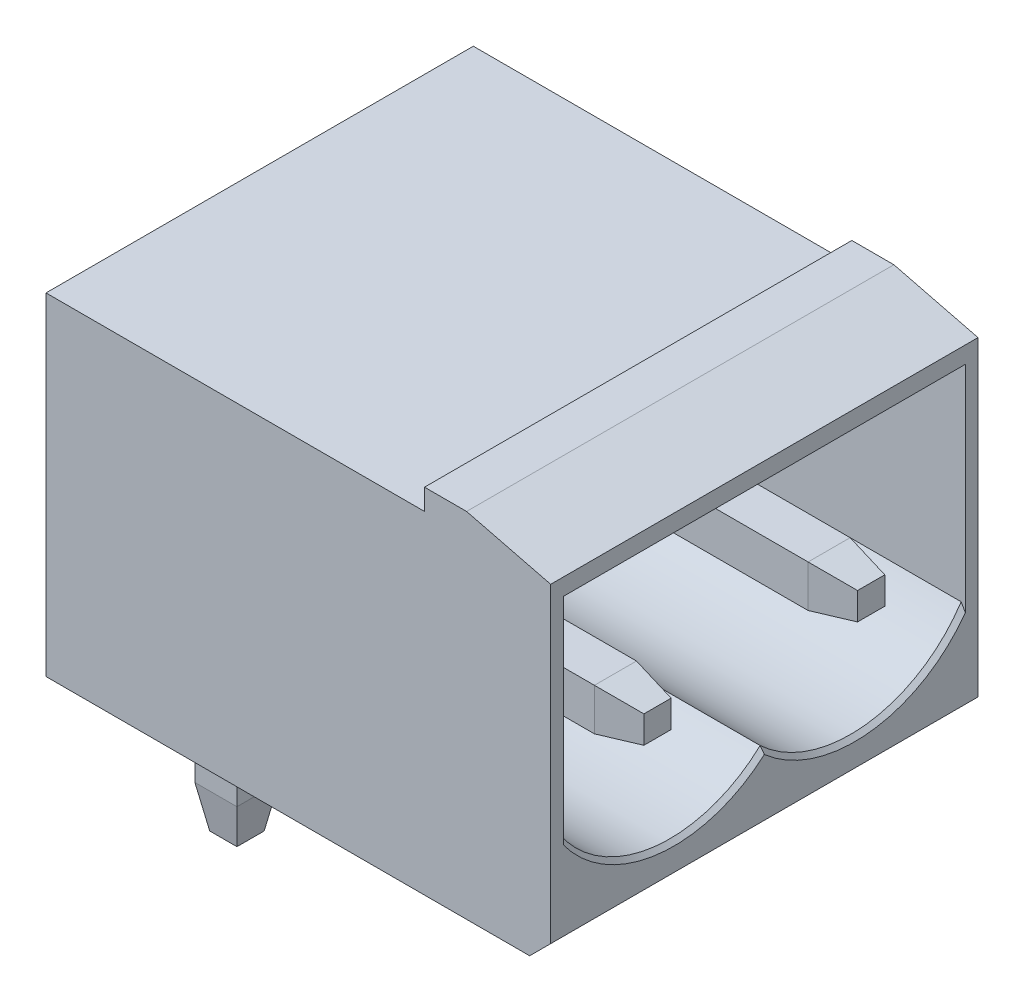
from build123d import *

# Parameters (mm, degrees)
SKIZZE3_W                       = 12
SKIZZE3_H                       = 7.9
AUFSATZ_LINEAR_AUSTRAGEN2_DEPTH = 10.16
AUFSATZ_LINEAR_AUSTRAGEN3_DEPTH = 10.16
SCHNITT_LINEAR_AUSTRAGEN1_DEPTH = 9
SKIZZE6_W                       = 1
SKIZZE6_H                       = 1
AUFSATZ_LINEAR_AUSTRAGEN4_DEPTH = 3.45
SKIZZE7_W                       = 1
SKIZZE7_H                       = 1
AUFSATZ_LINEAR_AUSTRAGEN5_DEPTH = 9
FASE1_SIZE                      = 1
FASE1_SIZE2                     = 0.176326981
FASE1_PART_2_SIZE               = 1
FASE1_PART_2_SIZE2              = 0.176326981
FASE1_PART_3_SIZE               = 1
FASE1_PART_3_SIZE2              = 0.176326981
FASE1_PART_4_SIZE               = 1
FASE1_PART_4_SIZE2              = 0.176326981
FASE1_PART_5_SIZE               = 1
FASE1_PART_5_SIZE2              = 0.176326981
FASE1_PART_6_SIZE               = 1
FASE1_PART_6_SIZE2              = 0.176326981
FASE1_PART_7_SIZE               = 1
FASE1_PART_7_SIZE2              = 0.176326981
FASE1_PART_8_SIZE               = 1
FASE1_PART_8_SIZE2              = 0.176326981
FASE14_SIZE                     = 1
FASE14_SIZE2                    = 0.176326981
FASE14_PART_2_SIZE              = 1
FASE14_PART_2_SIZE2             = 0.176326981
FASE14_PART_3_SIZE              = 1
FASE14_PART_3_SIZE2             = 0.176326981
FASE14_PART_4_SIZE              = 1
FASE14_PART_4_SIZE2             = 0.176326981
FASE14_PART_5_SIZE              = 1
FASE14_PART_5_SIZE2             = 0.176326981
FASE14_PART_6_SIZE              = 1
FASE14_PART_6_SIZE2             = 0.176326981
FASE14_PART_7_SIZE              = 1
FASE14_PART_7_SIZE2             = 0.176326981
FASE14_PART_8_SIZE              = 1
FASE14_PART_8_SIZE2             = 0.176326981
FASE15_SIZE                     = 0.1
FASE16_SIZE                     = 0.5


with BuildPart() as part:
    # Skizze3 → Aufsatz-Linear austragen2 (new body)
    with BuildSketch(Plane.XY):
        Rectangle(SKIZZE3_W, SKIZZE3_H)
    extrude(amount=AUFSATZ_LINEAR_AUSTRAGEN2_DEPTH)

    # Skizze4 → Aufsatz-Linear austragen3 (add, through all)
    with BuildSketch(Plane.XY.offset(10.16)):
        Polygon((3, 3.95), (3, 4.45), (4, 4.45), (6, 3.95), align=None)
    extrude(amount=-AUFSATZ_LINEAR_AUSTRAGEN3_DEPTH)

    # Skizze5 → Schnitt-Linear austragen1 (cut)
    with BuildSketch(Plane(origin=(6, 0, 0), x_dir=(0, 0, -1), z_dir=(1, 0, 0))):
        with BuildLine():
            Line((-9.86, 3.45), (-9.86, -1.39))
            ThreePointArc((-9.86, -1.39), (-7.602375704, -2.785098012), (-5.08, -1.96))
            ThreePointArc((-5.08, -1.96), (-2.557624296, -2.785098012), (-0.3, -1.39))
            Line((-0.3, -1.39), (-0.3, 3.45))
            Line((-0.3, 3.45), (-9.86, 3.45))
        make_face()
    extrude(amount=-SCHNITT_LINEAR_AUSTRAGEN1_DEPTH, mode=Mode.SUBTRACT)

    # Skizze6 → Aufsatz-Linear austragen4 (add)
    with BuildSketch(Plane(origin=(0, -3.95, 0), x_dir=(-1, 0, 0), z_dir=(0, -1, 0))):
        with Locations((4, -7.62)):
            Rectangle(SKIZZE6_W, SKIZZE6_H)
        with Locations((4, -2.54)):
            Rectangle(SKIZZE6_W, SKIZZE6_H)
    extrude(amount=AUFSATZ_LINEAR_AUSTRAGEN4_DEPTH)

    # Skizze7 → Aufsatz-Linear austragen5 (add)
    with BuildSketch(Plane(origin=(-3, 0, 0), x_dir=(0, 0, -1), z_dir=(1, 0, 0))):
        with Locations((-7.62, -0.15)):
            Rectangle(SKIZZE7_W, SKIZZE7_H)
        with Locations((-2.54, -0.15)):
            Rectangle(SKIZZE7_W, SKIZZE7_H)
    extrude(amount=AUFSATZ_LINEAR_AUSTRAGEN5_DEPTH)

    # Fase1
    fase1_edges = [part.edges().sort_by_distance(p)[0] for p in [
        (-3.5, -7.4, 7.62),
    ]]
    fase1_side = [part.faces().sort_by_distance(p)[0] for p in [
        (-3.5, -5.675, 7.62),
    ]]
    chamfer(fase1_edges, length=FASE1_SIZE, length2=FASE1_SIZE2, reference=fase1_side[0])

    # Fase1 part 2
    fase1_part_2_edges = [part.edges().sort_by_distance(p)[0] for p in [
        (-4, -7.4, 8.12),
    ]]
    fase1_part_2_side = [part.faces().sort_by_distance(p)[0] for p in [
        (-4, -5.675, 8.12),
    ]]
    chamfer(fase1_part_2_edges, length=FASE1_PART_2_SIZE, length2=FASE1_PART_2_SIZE2, reference=fase1_part_2_side[0])

    # Fase1 part 3
    fase1_part_3_edges = [part.edges().sort_by_distance(p)[0] for p in [
        (-4.5, -7.4, 7.62),
    ]]
    fase1_part_3_side = [part.faces().sort_by_distance(p)[0] for p in [
        (-4.5, -5.675, 7.62),
    ]]
    chamfer(fase1_part_3_edges, length=FASE1_PART_3_SIZE, length2=FASE1_PART_3_SIZE2, reference=fase1_part_3_side[0])

    # Fase1 part 4
    fase1_part_4_edges = [part.edges().sort_by_distance(p)[0] for p in [
        (-4, -7.4, 7.12),
    ]]
    fase1_part_4_side = [part.faces().sort_by_distance(p)[0] for p in [
        (-4, -5.675, 7.12),
    ]]
    chamfer(fase1_part_4_edges, length=FASE1_PART_4_SIZE, length2=FASE1_PART_4_SIZE2, reference=fase1_part_4_side[0])

    # Fase1 part 5
    fase1_part_5_edges = [part.edges().sort_by_distance(p)[0] for p in [
        (-4.5, -7.4, 2.54),
    ]]
    fase1_part_5_side = [part.faces().sort_by_distance(p)[0] for p in [
        (-4.5, -5.675, 2.54),
    ]]
    chamfer(fase1_part_5_edges, length=FASE1_PART_5_SIZE, length2=FASE1_PART_5_SIZE2, reference=fase1_part_5_side[0])

    # Fase1 part 6
    fase1_part_6_edges = [part.edges().sort_by_distance(p)[0] for p in [
        (-4, -7.4, 2.04),
    ]]
    fase1_part_6_side = [part.faces().sort_by_distance(p)[0] for p in [
        (-4, -5.675, 2.04),
    ]]
    chamfer(fase1_part_6_edges, length=FASE1_PART_6_SIZE, length2=FASE1_PART_6_SIZE2, reference=fase1_part_6_side[0])

    # Fase1 part 7
    fase1_part_7_edges = [part.edges().sort_by_distance(p)[0] for p in [
        (-3.5, -7.4, 2.54),
    ]]
    fase1_part_7_side = [part.faces().sort_by_distance(p)[0] for p in [
        (-3.5, -5.675, 2.54),
    ]]
    chamfer(fase1_part_7_edges, length=FASE1_PART_7_SIZE, length2=FASE1_PART_7_SIZE2, reference=fase1_part_7_side[0])

    # Fase1 part 8
    fase1_part_8_edges = [part.edges().sort_by_distance(p)[0] for p in [
        (-4, -7.4, 3.04),
    ]]
    fase1_part_8_side = [part.faces().sort_by_distance(p)[0] for p in [
        (-4, -5.675, 3.04),
    ]]
    chamfer(fase1_part_8_edges, length=FASE1_PART_8_SIZE, length2=FASE1_PART_8_SIZE2, reference=fase1_part_8_side[0])

    # Fase14
    fase14_edges = [part.edges().sort_by_distance(p)[0] for p in [
        (6, -0.65, 7.62),
    ]]
    fase14_side = [part.faces().sort_by_distance(p)[0] for p in [
        (1.5, -0.65, 7.62),
    ]]
    chamfer(fase14_edges, length=FASE14_SIZE, length2=FASE14_SIZE2, reference=fase14_side[0])

    # Fase14 part 2
    fase14_part_2_edges = [part.edges().sort_by_distance(p)[0] for p in [
        (6, -0.15, 8.12),
    ]]
    fase14_part_2_side = [part.faces().sort_by_distance(p)[0] for p in [
        (1.5, -0.15, 8.12),
    ]]
    chamfer(fase14_part_2_edges, length=FASE14_PART_2_SIZE, length2=FASE14_PART_2_SIZE2, reference=fase14_part_2_side[0])

    # Fase14 part 3
    fase14_part_3_edges = [part.edges().sort_by_distance(p)[0] for p in [
        (6, 0.35, 7.62),
    ]]
    fase14_part_3_side = [part.faces().sort_by_distance(p)[0] for p in [
        (1.5, 0.35, 7.62),
    ]]
    chamfer(fase14_part_3_edges, length=FASE14_PART_3_SIZE, length2=FASE14_PART_3_SIZE2, reference=fase14_part_3_side[0])

    # Fase14 part 4
    fase14_part_4_edges = [part.edges().sort_by_distance(p)[0] for p in [
        (6, -0.15, 7.12),
    ]]
    fase14_part_4_side = [part.faces().sort_by_distance(p)[0] for p in [
        (1.5, -0.15, 7.12),
    ]]
    chamfer(fase14_part_4_edges, length=FASE14_PART_4_SIZE, length2=FASE14_PART_4_SIZE2, reference=fase14_part_4_side[0])

    # Fase14 part 5
    fase14_part_5_edges = [part.edges().sort_by_distance(p)[0] for p in [
        (6, -0.15, 3.04),
    ]]
    fase14_part_5_side = [part.faces().sort_by_distance(p)[0] for p in [
        (1.5, -0.15, 3.04),
    ]]
    chamfer(fase14_part_5_edges, length=FASE14_PART_5_SIZE, length2=FASE14_PART_5_SIZE2, reference=fase14_part_5_side[0])

    # Fase14 part 6
    fase14_part_6_edges = [part.edges().sort_by_distance(p)[0] for p in [
        (6, 0.35, 2.54),
    ]]
    fase14_part_6_side = [part.faces().sort_by_distance(p)[0] for p in [
        (1.5, 0.35, 2.54),
    ]]
    chamfer(fase14_part_6_edges, length=FASE14_PART_6_SIZE, length2=FASE14_PART_6_SIZE2, reference=fase14_part_6_side[0])

    # Fase14 part 7
    fase14_part_7_edges = [part.edges().sort_by_distance(p)[0] for p in [
        (6, -0.15, 2.04),
    ]]
    fase14_part_7_side = [part.faces().sort_by_distance(p)[0] for p in [
        (1.5, -0.15, 2.04),
    ]]
    chamfer(fase14_part_7_edges, length=FASE14_PART_7_SIZE, length2=FASE14_PART_7_SIZE2, reference=fase14_part_7_side[0])

    # Fase14 part 8
    fase14_part_8_edges = [part.edges().sort_by_distance(p)[0] for p in [
        (6, -0.65, 2.54),
    ]]
    fase14_part_8_side = [part.faces().sort_by_distance(p)[0] for p in [
        (1.5, -0.65, 2.54),
    ]]
    chamfer(fase14_part_8_edges, length=FASE14_PART_8_SIZE, length2=FASE14_PART_8_SIZE2, reference=fase14_part_8_side[0])

    # Fase15
    fase15_edges = [part.edges().sort_by_distance(p)[0] for p in [
        (6, 3.45, 5.08),
        (6, -2.785098012, 7.602375704),
        (6, -2.785098012, 2.557624296),
    ]]
    chamfer(fase15_edges, length=FASE15_SIZE)

    # Fase16
    fase16_edges = [part.edges().sort_by_distance(p)[0] for p in [
        (6, -3.95, 5.08),
    ]]
    chamfer(fase16_edges, length=FASE16_SIZE)


solid = part.part
